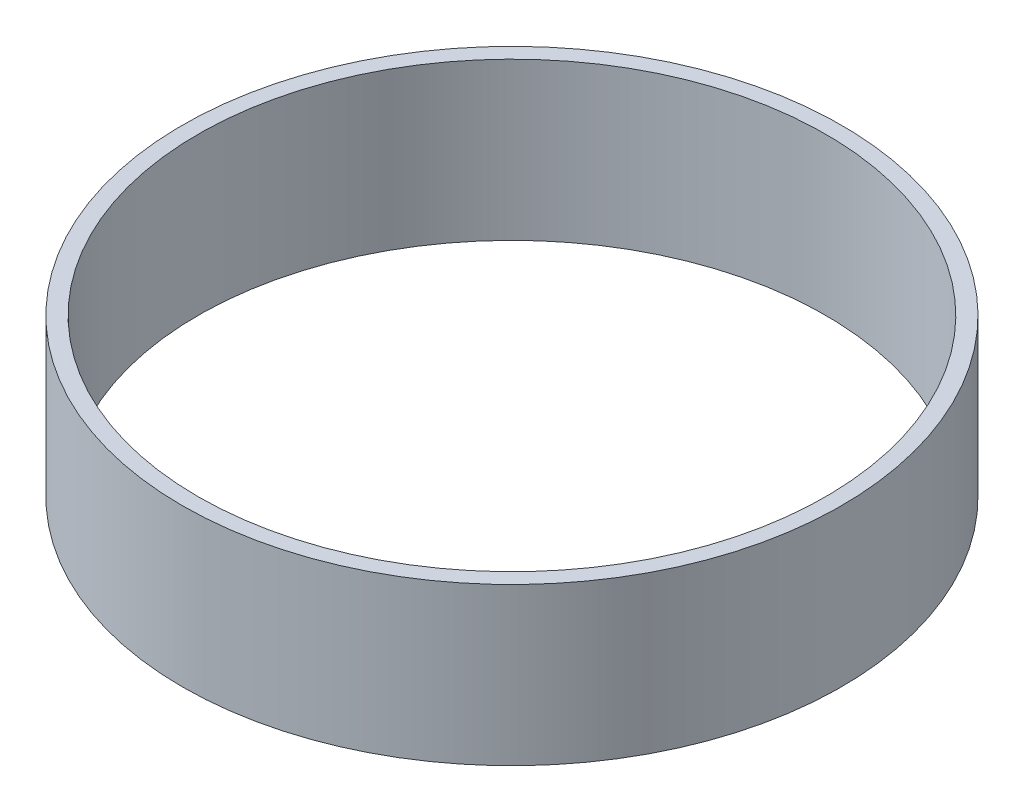
from build123d import *

# Parameters (mm, degrees)
SKETCH1_R           = 21
SKETCH1_R_2         = 20
BOSS_EXTRUDE1_DEPTH = 10


with BuildPart() as part:
    # Sketch1 → Boss-Extrude1 (new body)
    with BuildSketch(Plane(origin=(0, 0, 0), x_dir=(1, 0, 0), z_dir=(0, 1, 0))):
        Circle(SKETCH1_R)
        Circle(SKETCH1_R_2, mode=Mode.SUBTRACT)
    extrude(amount=BOSS_EXTRUDE1_DEPTH)


solid = part.part
